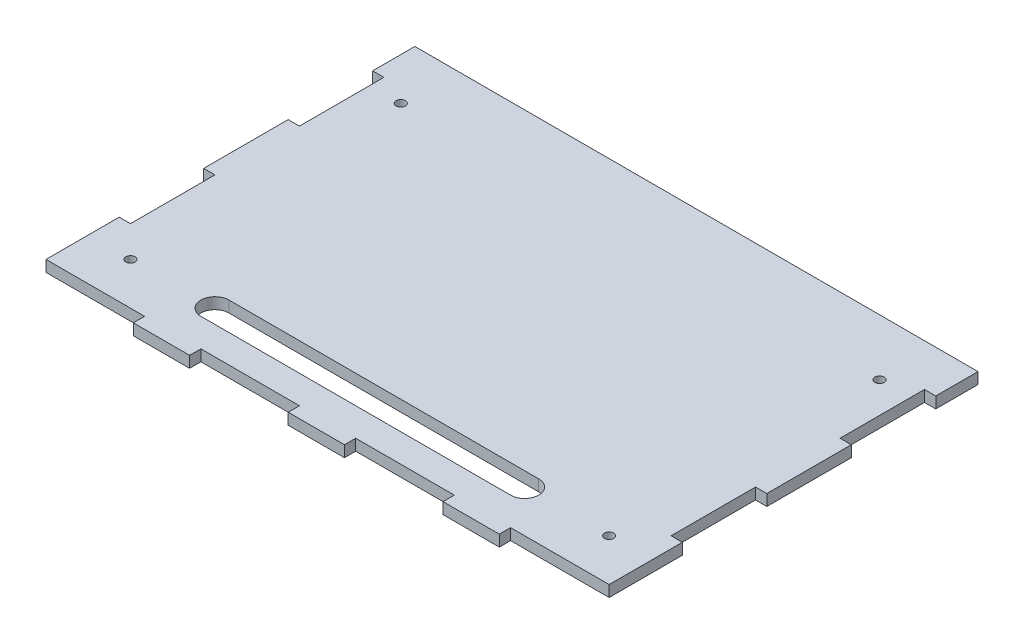
from build123d import *

# Parameters (mm, degrees)
ESBO_O1_W                               = 200
ESBO_O1_H                               = 150
RESSALTO_EXTRUS_O1_DEPTH                = 4
ESBO_O2_W                               = 35
ESBO_O2_H                               = 4
ESBO_O2_W_2                             = 4
ESBO_O2_H_2                             = 30
CORTE_EXTRUS_O1_DEPTH                   = 5
ESBO_O3_W                               = 200
ESBO_O3_H                               = 15
CORTE_EXTRUS_O2_DEPTH                   = 5
BROCA_DE_ROSQUEAR_PARA_TARRAXA_DE_M41_D = 3.3
ESBO_O5_R                               = 1.65
CORTE_EXTRUS_O3_DEPTH                   = 5


with BuildPart() as part:
    # Esboço1 → Ressalto-extrusão1 (new body)
    with BuildSketch(Plane(origin=(0, 0, 0), x_dir=(1, 0, 0), z_dir=(0, 1, 0))):
        Rectangle(ESBO_O1_W, ESBO_O1_H)
    extrude(amount=RESSALTO_EXTRUS_O1_DEPTH)

    # Esboço2 → Corte-extrusão1 (cut, through all)
    with BuildSketch(Plane(origin=(0, 4, 0), x_dir=(1, 0, 0), z_dir=(0, 1, 0))):
        with Locations((-27.5, -73)):
            Rectangle(ESBO_O2_W, ESBO_O2_H)
        with Locations((27.5, -73)):
            Rectangle(ESBO_O2_W, ESBO_O2_H)
        with Locations((82.5, -73)):
            Rectangle(ESBO_O2_W, ESBO_O2_H)
        with Locations((-82.5, -73)):
            Rectangle(ESBO_O2_W, ESBO_O2_H)
        with Locations((98, 30)):
            Rectangle(ESBO_O2_W_2, ESBO_O2_H_2)
        with Locations((98, -30)):
            Rectangle(ESBO_O2_W_2, ESBO_O2_H_2)
        with Locations((-98, 30)):
            Rectangle(ESBO_O2_W_2, ESBO_O2_H_2)
        with Locations((-98, -30)):
            Rectangle(ESBO_O2_W_2, ESBO_O2_H_2)
    extrude(amount=-CORTE_EXTRUS_O1_DEPTH, mode=Mode.SUBTRACT)

    # Esboço3 → Corte-extrusão2 (cut, through all)
    with BuildSketch(Plane(origin=(0, 4, 0), x_dir=(1, 0, 0), z_dir=(0, 1, 0))):
        with Locations((0, 67.5)):
            Rectangle(ESBO_O3_W, ESBO_O3_H)
    extrude(amount=-CORTE_EXTRUS_O2_DEPTH, mode=Mode.SUBTRACT)

    # Broca de rosquear para tarraxa de M41 (through all)
    with Locations(Plane(origin=(-85, 4, -40), x_dir=(0, 0, 1), z_dir=(0, 1, 0))):
        with Locations((0, 0), (96, 0), (96, 170), (0, 170)):
            Hole(BROCA_DE_ROSQUEAR_PARA_TARRAXA_DE_M41_D / 2)

    # Esboço5 → Corte-extrusão3 (cut, through all)
    with BuildSketch(Plane(origin=(0, 4, 0), x_dir=(1, 0, 0), z_dir=(0, 1, 0))):
        with Locations((-85, -56)):
            Circle(ESBO_O5_R)
        with BuildLine():
            Line((55, -61), (-55, -61))
            ThreePointArc((-55, -61), (-60, -56), (-55, -51))
            Line((-55, -51), (55, -51))
            ThreePointArc((55, -51), (60, -56), (55, -61))
        make_face()
    extrude(amount=-CORTE_EXTRUS_O3_DEPTH, mode=Mode.SUBTRACT)


solid = part.part
